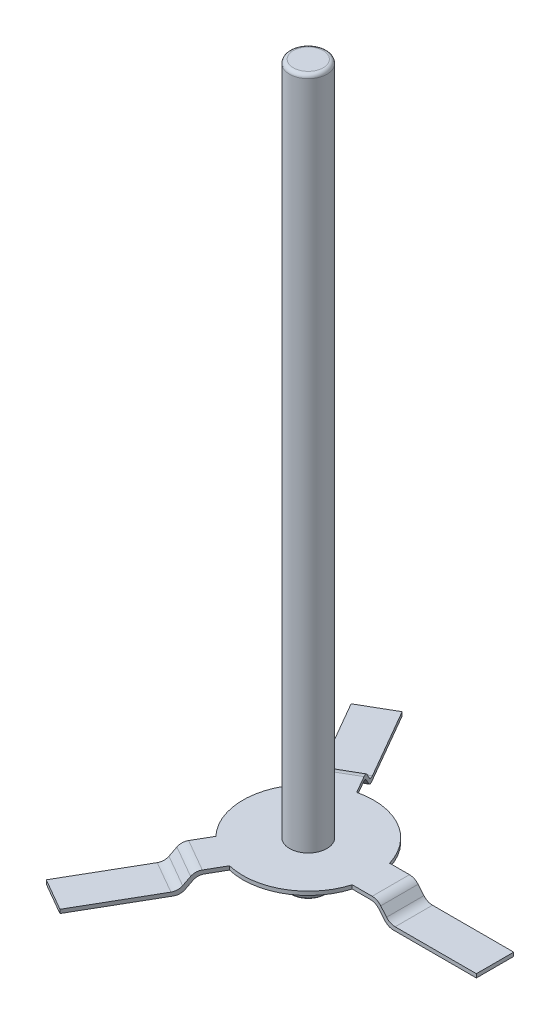
from build123d import *

# Parameters (mm, degrees)
SKETCH_1_R               = 0.5
EXTRUDE_1_DEPTH          = 19.15
SKETCH_2_R               = 1.75
SKETCH_2_R_2             = 0.5
EXTRUDE_2_DEPTH          = 0.1
EXTRUDE_3_DEPTH          = 0.5
PATTERN_CIRCULAR_1_COUNT = 3
FILLET_2_R               = 0.3
FILLET_3_R               = 0.1


with BuildPart() as part:
    # Эскиз1 → Бобышка-Вытянуть1 (new body)
    with BuildSketch(Plane(origin=(0, 0, 0), x_dir=(1, 0, 0), z_dir=(0, 1, 0))):
        Circle(SKETCH_1_R)
    extrude(amount=EXTRUDE_1_DEPTH)

    # Эскиз2 → Бобышка-Вытянуть2 (add)
    with BuildSketch(Plane(origin=(0, 1, 0), x_dir=(1, 0, 0), z_dir=(0, 1, 0))):
        Circle(SKETCH_2_R)
        Circle(SKETCH_2_R_2, mode=Mode.SUBTRACT)
    extrude(amount=EXTRUDE_2_DEPTH)

    # Эскиз3 → Бобышка-Вытянуть3 (add, symmetric)
    with BuildSketch(Plane.XY):
        Polygon((1.5, 1), (2.303369234, 1), (2.639009087, 0.6), (5, 0.6), (5, 0.7), (2.685639852, 0.7), (2.35, 1.1), (1.5, 1.1), align=None)
    extrude_3 = extrude(amount=EXTRUDE_3_DEPTH, both=True)

    # Круговой массив1: Бобышка-Вытянуть3 ×3 about axis
    pattern_circular_1_axis = Axis((0, 0, 0), (0, 1, 0))
    for i in range(1, PATTERN_CIRCULAR_1_COUNT):
        add(extrude_3.rotate(pattern_circular_1_axis, i * 360 / PATTERN_CIRCULAR_1_COUNT))

    # Скругление2
    fillet_2_edges = [part.edges().sort_by_distance(p)[0] for p in [
        (2.303369234, 1, 0),
        (2.639009087, 0.6, 0),
        (2.685639852, 0.7, 0),
        (2.35, 1.1, 0),
        (-1.151684617, 1, -1.994776271),
        (-1.319504543, 0.6, -2.28544891),
        (-1.342819926, 0.7, -2.325832338),
        (-1.175, 1.1, -2.035159699),
        (-1.151684617, 1, 1.994776271),
        (-1.319504543, 0.6, 2.28544891),
        (-1.342819926, 0.7, 2.325832338),
        (-1.175, 1.1, 2.035159699),
    ]]
    fillet(fillet_2_edges, radius=FILLET_2_R)

    # Скругление3
    fillet_3_edges = [part.edges().sort_by_distance(p)[0] for p in [
        (-0.5, 0, 0),
        (-0.5, 19.15, 0),
    ]]
    fillet(fillet_3_edges, radius=FILLET_3_R)


solid = part.part
